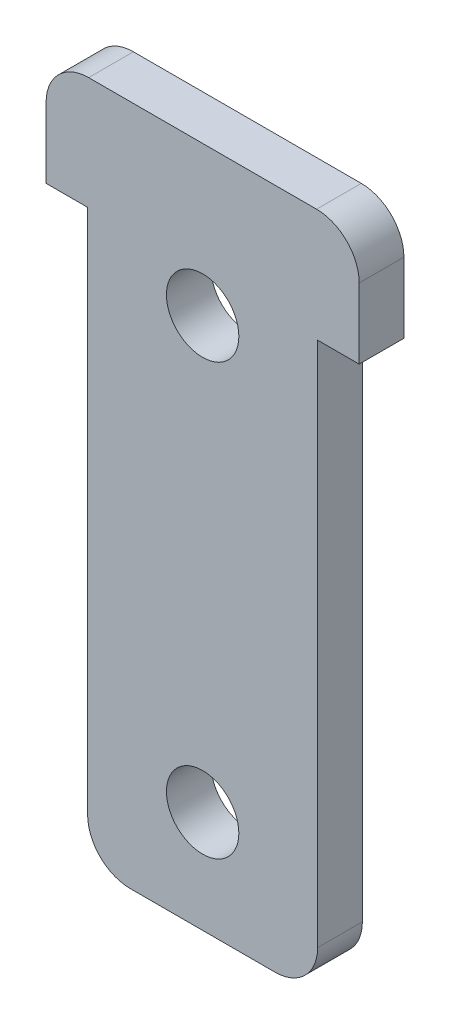
from build123d import *

# Parameters (mm, degrees)
SKETCH1_R           = 1.7
BOSS_EXTRUDE1_DEPTH = 2.1


with BuildPart() as part:
    # Sketch1 → Boss-Extrude1 (new body)
    with BuildSketch(Plane.XY):
        with BuildLine():
            ThreePointArc((0, 2), (0.585786438, 0.585786438), (2, 0))
            Line((2, 0), (8.8, 0))
            ThreePointArc((8.8, 0), (10.214213562, 0.585786438), (10.8, 2))
            Line((10.8, 2), (10.8, 26.7))
            Line((10.8, 26.7), (12.75, 26.7))
            Line((12.75, 26.7), (12.75, 30))
            ThreePointArc((12.75, 30), (12.164213562, 31.414213562), (10.75, 32))
            Line((10.75, 32), (0.05, 32))
            ThreePointArc((0.05, 32), (-1.364213562, 31.414213562), (-1.95, 30))
            Line((-1.95, 30), (-1.95, 26.7))
            Line((-1.95, 26.7), (0, 26.7))
            Line((0, 26.7), (0, 2))
        make_face()
        with Locations((5.4, 4.8)):
            Circle(SKETCH1_R, mode=Mode.SUBTRACT)
        with Locations((5.4, 25)):
            Circle(SKETCH1_R, mode=Mode.SUBTRACT)
    extrude(amount=BOSS_EXTRUDE1_DEPTH)


solid = part.part
